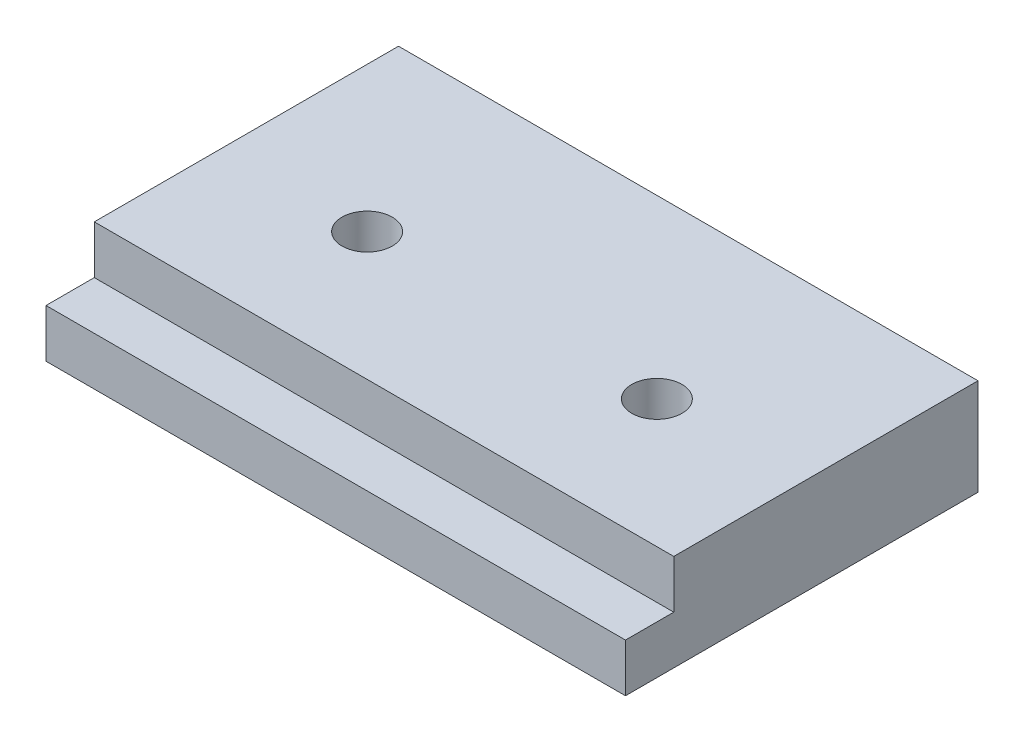
from build123d import *

# Parameters (mm, degrees)
SKETCH1_W                   = 60
SKETCH1_H                   = 36.5
BOSS_EXTRUDE1_DEPTH         = 10
SKETCH2_W                   = 60
SKETCH2_H                   = 5
CUT_EXTRUDE1_DEPTH          = 5
TAP_DRILL_FOR_M5_TAP1_D     = 5.2
TAP_DRILL_FOR_M5_TAP1_DEPTH = 46
TAP_DRILL_FOR_M5_TAP1_TIP   = 1.562237609


with BuildPart() as part:
    # Sketch1 → Boss-Extrude1 (new body)
    with BuildSketch(Plane(origin=(0, 0, 0), x_dir=(1, 0, 0), z_dir=(0, 1, 0))):
        Rectangle(SKETCH1_W, SKETCH1_H)
    extrude(amount=BOSS_EXTRUDE1_DEPTH)

    # Sketch2 → Cut-Extrude1 (cut)
    with BuildSketch(Plane(origin=(0, 10, 0), x_dir=(1, 0, 0), z_dir=(0, 1, 0))):
        with Locations((0, -15.75)):
            Rectangle(SKETCH2_W, SKETCH2_H)
    extrude(amount=-CUT_EXTRUDE1_DEPTH, mode=Mode.SUBTRACT)

    # Tap Drill for M5 Tap1
    with Locations(Plane(origin=(-15, 10, 0), x_dir=(0, 0, 1), z_dir=(0, 1, 0))):
        with Locations((0, 0), (0, 30)):
            Hole(TAP_DRILL_FOR_M5_TAP1_D / 2, depth=TAP_DRILL_FOR_M5_TAP1_DEPTH)
            with Locations((0, 0, -(TAP_DRILL_FOR_M5_TAP1_DEPTH + TAP_DRILL_FOR_M5_TAP1_TIP / 2))):  # 118° drill point
                Cone(0, TAP_DRILL_FOR_M5_TAP1_D / 2, TAP_DRILL_FOR_M5_TAP1_TIP, mode=Mode.SUBTRACT)


solid = part.part
